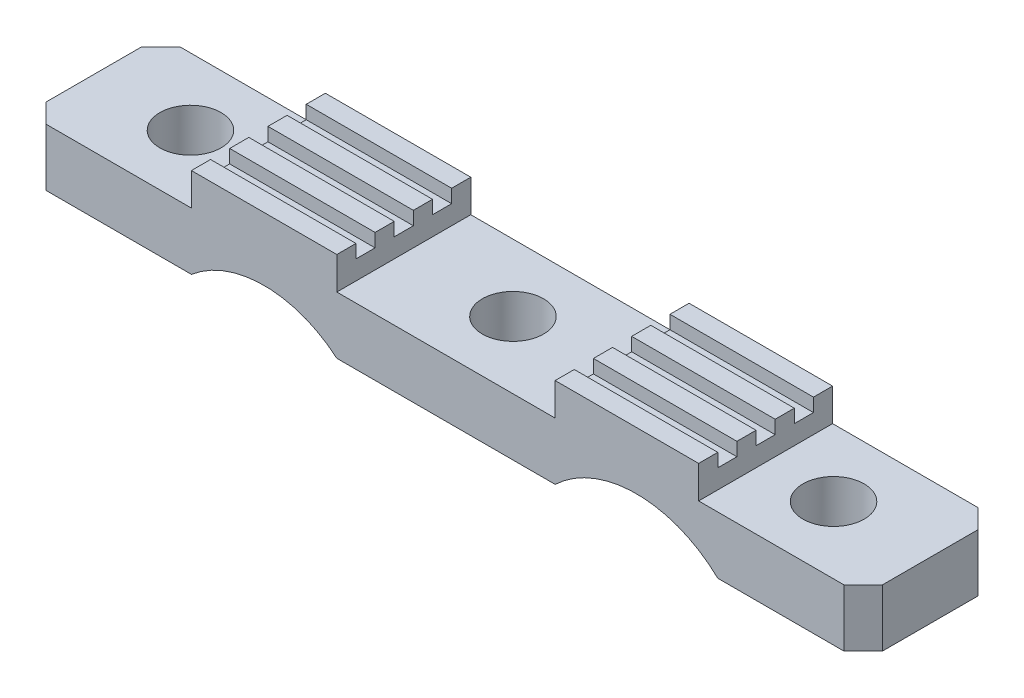
from build123d import *

# Parameters (mm, degrees)
BOSS_EXTRUDE1_DEPTH = 7
CUT_EXTRUDE1_DEPTH  = 28.51
SKETCH4_R           = 1.6
CUT_EXTRUDE2_DEPTH  = 3
SKETCH5_R           = 1.6
CUT_EXTRUDE3_DEPTH  = 3
SKETCH6_W           = 7
SKETCH6_H           = 0.3
CUT_EXTRUDE4_DEPTH  = 28.51
SKETCH8_W           = 7
SKETCH8_H           = 1.7
CUT_EXTRUDE6_DEPTH  = 1
SKETCH9_W           = 2.5
SKETCH9_H           = 7
BOSS_EXTRUDE2_DEPTH = 3
CUT_EXTRUDE7_DEPTH  = 7
CHAMFER1_SIZE       = 1
SKETCH11_W          = 7
SKETCH11_H          = 1.7
CUT_EXTRUDE8_DEPTH  = 1


with BuildPart() as part:
    # Sketch1 → Boss-Extrude1 (new body)
    with BuildSketch(Plane.XY):
        Polygon((17.01, -5), (17.01, -3), (8.51, -3), (8.51, -5), (8.41, -5), (-2.8, -5), (-2.9, -5), (-2.9, -3), (-11.5, -3), (-11.5, -5), (-11.6, -5), (-16.6, -5), (-16.6, -8), (22.11, -8), (22.11, -5), (17.11, -5), align=None)
    extrude(amount=-BOSS_EXTRUDE1_DEPTH)

    # Sketch2 → Cut-Extrude1 (cut)
    with BuildSketch(Plane.ZY.offset(11.5)):
        Polygon((0, -3), (-1, -3), (-1, -4), (-2, -4), (-2, -3), (-3, -3), (-3, -4), (-4, -4), (-4, -3), (-5, -3), (-5, -4), (-6, -4), (-6, -3), (-7, -3), (-7, -2.645827001), (0, -2.645827001), align=None)
    extrude(amount=-CUT_EXTRUDE1_DEPTH, mode=Mode.SUBTRACT)

    # Sketch4 → Cut-Extrude2 (cut)
    with BuildSketch(Plane(origin=(0, -5, 0), x_dir=(1, 0, 0), z_dir=(0, 1, 0))):
        with Locations((2.805, 3.5)):
            Circle(SKETCH4_R)
    extrude(amount=-CUT_EXTRUDE2_DEPTH, mode=Mode.SUBTRACT)

    # Sketch5 → Cut-Extrude3 (cut)
    with BuildSketch(Plane(origin=(0, -5, 0), x_dir=(1, 0, 0), z_dir=(0, 1, 0))):
        with Locations((-14.05, 3.5)):
            Circle(SKETCH5_R)
        with Locations((19.56, 3.5)):
            Circle(SKETCH5_R)
    extrude(amount=-CUT_EXTRUDE3_DEPTH, mode=Mode.SUBTRACT)

    # Sketch6 → Cut-Extrude4 (cut)
    with BuildSketch(Plane(origin=(17.01, 0, 0), x_dir=(0, 0, -1), z_dir=(1, 0, 0))):
        with Locations((3.5, -3.15)):
            Rectangle(SKETCH6_W, SKETCH6_H)
    extrude(amount=-CUT_EXTRUDE4_DEPTH, mode=Mode.SUBTRACT)

    # Sketch8 → Cut-Extrude6 (cut)
    with BuildSketch(Plane.ZY.offset(11.5)):
        with Locations((-3.5, -4.15)):
            Rectangle(SKETCH8_W, SKETCH8_H)
    extrude(amount=-CUT_EXTRUDE6_DEPTH, mode=Mode.SUBTRACT)

    # Sketch9 → Boss-Extrude2 (add)
    with BuildSketch(Plane.XZ.offset(8)):
        with Locations((-17.85, -3.5)):
            Rectangle(SKETCH9_W, SKETCH9_H)
        with Locations((23.36, -3.5)):
            Rectangle(SKETCH9_W, SKETCH9_H)
    extrude(amount=-BOSS_EXTRUDE2_DEPTH)

    # Sketch10 → Cut-Extrude7 (cut)
    with BuildSketch(Plane(origin=(0, 0, -7), x_dir=(-1, 0, 0), z_dir=(0, 0, -1))):
        with BuildLine():
            Line((-17.01, -8), (-8.51, -8))
            ThreePointArc((-8.51, -8), (-12.76, -6.3), (-17.01, -8))
        make_face()
        with BuildLine():
            Line((2.9, -8), (10.5, -8))
            ThreePointArc((10.5, -8), (6.7, -6.601279457), (2.9, -8))
        make_face()
    extrude(amount=-CUT_EXTRUDE7_DEPTH, mode=Mode.SUBTRACT)

    # Chamfer1
    chamfer1_edges = [part.edges().sort_by_distance(p)[0] for p in [
        (-19.1, -6.5, -7),
        (-19.1, -6.5, 0),
        (24.61, -6.5, 0),
        (24.61, -6.5, -7),
    ]]
    chamfer(chamfer1_edges, length=CHAMFER1_SIZE)

    # Sketch11 → Cut-Extrude8 (cut)
    with BuildSketch(Plane(origin=(17.01, 0, 0), x_dir=(0, 0, -1), z_dir=(1, 0, 0))):
        with Locations((3.5, -4.15)):
            Rectangle(SKETCH11_W, SKETCH11_H)
    extrude(amount=-CUT_EXTRUDE8_DEPTH, mode=Mode.SUBTRACT)


solid = part.part
